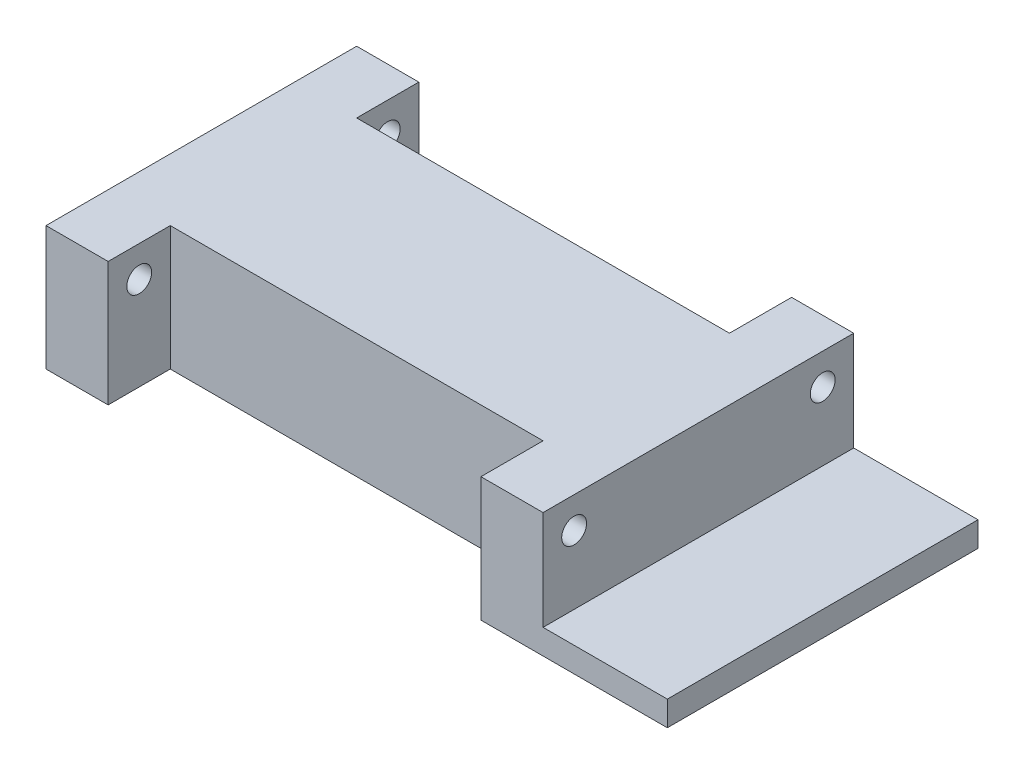
from build123d import *

# Parameters (mm, degrees)
SKETCH2_W           = 400
SKETCH2_H           = 150
BOSS_EXTRUDE1_DEPTH = 50
SKETCH3_W           = 50
SKETCH3_H           = 50
BOSS_EXTRUDE2_DEPTH = 50
SKETCH4_R           = 10
CUT_EXTRUDE1_DEPTH  = 444
BOSS_EXTRUDE3_DEPTH = 50
SKETCH7_W           = 250
SKETCH7_H           = 20
BOSS_EXTRUDE4_DEPTH = 100


with BuildPart() as part:
    # Sketch2 → Boss-Extrude1 (new body)
    with BuildSketch(Plane(origin=(0, 0, 0), x_dir=(1, 0, 0), z_dir=(0, 1, 0))):
        with Locations((200, 75)):
            Rectangle(SKETCH2_W, SKETCH2_H)
    extrude(amount=BOSS_EXTRUDE1_DEPTH)

    # Sketch3 → Boss-Extrude2 (add)
    with BuildSketch(Plane(origin=(400, 0, 0), x_dir=(0, 0, -1), z_dir=(1, 0, 0))):
        with Locations((-25, 25)):
            Rectangle(SKETCH3_W, SKETCH3_H)
        with Locations((175, 25)):
            Rectangle(SKETCH3_W, SKETCH3_H)
    boss_extrude2 = extrude(amount=-BOSS_EXTRUDE2_DEPTH)

    # Mirror4: Boss-Extrude2 across plane
    add(boss_extrude2.mirror(Plane(origin=(200, 0, 0), x_dir=(0, 0, 1), z_dir=(1, 0, 0))))

    # Sketch4 → Cut-Extrude1 (cut)
    with BuildSketch(Plane(origin=(400, 0, 0), x_dir=(0, 0, -1), z_dir=(1, 0, 0))):
        with Locations((-25, 25)):
            Circle(SKETCH4_R)
        with Locations((175, 25)):
            Circle(SKETCH4_R)
    extrude(amount=-CUT_EXTRUDE1_DEPTH, mode=Mode.SUBTRACT)

    # Sketch6 → Boss-Extrude3 (add)
    with BuildSketch(Plane.XZ):
        Polygon((0, 50), (0, -200), (50, -200), (50, -150), (350, -150), (350, -200), (400, -200), (400, 50), (350, 50), (350, 0), (50, 0), (50, 50), align=None)
    extrude(amount=BOSS_EXTRUDE3_DEPTH)

    # Sketch7 → Boss-Extrude4 (add)
    with BuildSketch(Plane(origin=(400, 0, 0), x_dir=(0, 0, -1), z_dir=(1, 0, 0))):
        with Locations((75, -40)):
            Rectangle(SKETCH7_W, SKETCH7_H)
    extrude(amount=BOSS_EXTRUDE4_DEPTH)


solid = part.part
